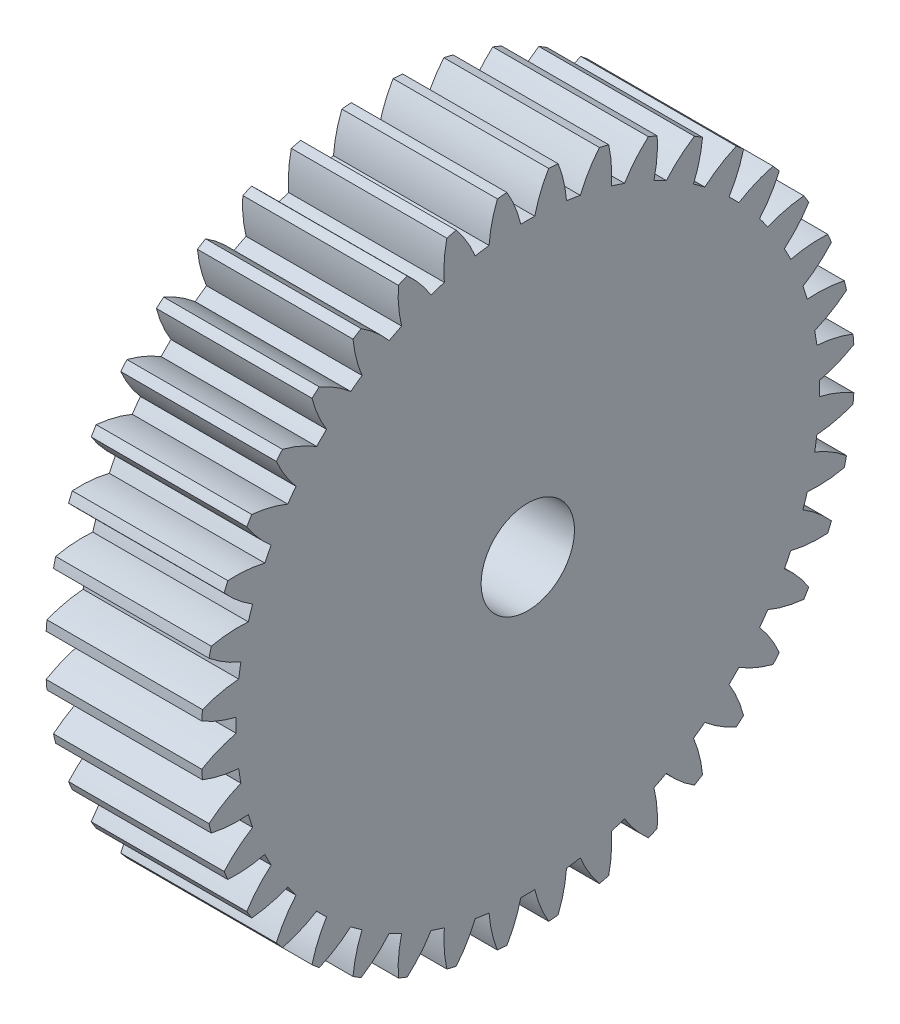
from build123d import *

# Parameters (mm, degrees)
BASPROSKE_W     = 5
BASPROSKE_H     = 10.5
TOOTHCUT_DEPTH  = 16.668439616
TEETHCUTS_COUNT = 40
TEETHCUTS_ANGLE = 351
BORSKE_R        = 1.5
BORE_DEPTH      = 50.0000508


with BuildPart() as part:
    # BasProSke → Base-Revolve (revolve)
    with BuildSketch(Plane(origin=(0, 0, 0), x_dir=(1, 0, 0), z_dir=(0, 1, 0)), mode=Mode.PRIVATE) as base_revolve_sk:
        with Locations((2.5, 5.25)):
            Rectangle(BASPROSKE_W, BASPROSKE_H)
    revolve(base_revolve_sk.sketch.rotate(Axis((-10, 0, 0), (1, 0, 0)), 180), axis=Axis((-10, 0, 0), (1, 0, 0)))

    # TooCutSke → ToothCut (cut, through all)
    with BuildSketch(Plane(origin=(0, 0, 0), x_dir=(0, 0, -1), z_dir=(1, 0, 0))):
        with BuildLine():
            ThreePointArc((0.22421855, 9.371318053), (0, 9.374), (-0.22421855, 9.371318053))
            ThreePointArc((-0.22421855, 9.371318053), (-0.410979984, 9.954898379), (-0.684682827, 10.503106902))
            ThreePointArc((-0.684682827, 10.503106902), (0, 10.5254), (0.684682827, 10.503106902))
            ThreePointArc((0.684682827, 10.503106902), (0.410979984, 9.954898379), (0.22421855, 9.371318053))
        make_face()
    toothcut = extrude(amount=TOOTHCUT_DEPTH, mode=Mode.SUBTRACT)

    # TeethCuts: ToothCut ×40 about axis
    teethcuts_axis = Axis((-10, 0, 0), (1, 0, 0))
    for i in range(1, TEETHCUTS_COUNT):
        add(toothcut.rotate(teethcuts_axis, i * TEETHCUTS_ANGLE / (TEETHCUTS_COUNT - 1)), mode=Mode.SUBTRACT)

    # BorSke → Bore (cut, symmetric)
    with BuildSketch(Plane(origin=(0, 0, 0), x_dir=(0, 0, -1), z_dir=(1, 0, 0))):
        with Locations(Location((0, 0, 0), (0, 0, 180))):
            Circle(BORSKE_R)
    extrude(amount=BORE_DEPTH, both=True, mode=Mode.SUBTRACT)


solid = part.part
